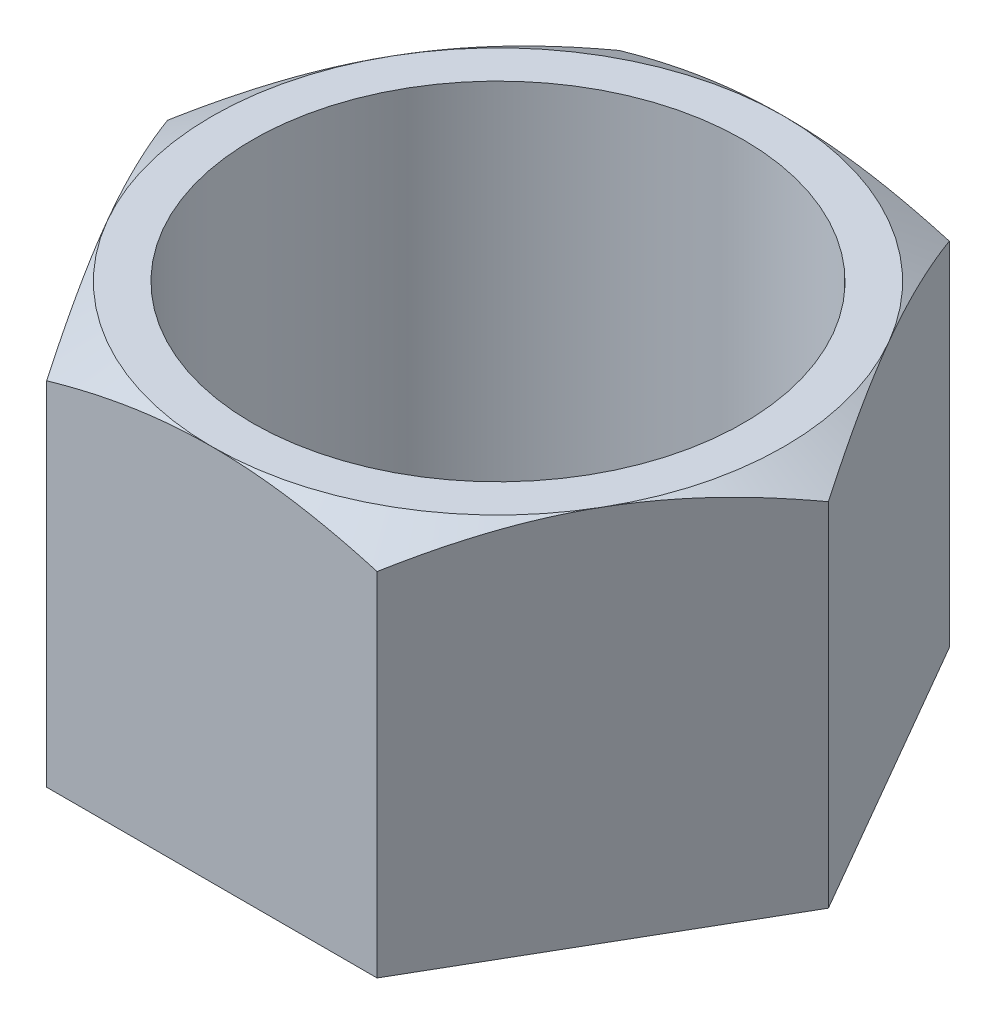
from build123d import *

# Parameters (mm, degrees)
BOSS_EXTRUDE1_DEPTH = 20
SKETCH2_OUTSIDE_W   = 116.37
SKETCH2_OUTSIDE_H   = 111.68
SKETCH2_OUTSIDE_R   = 15.155444566
CUT_EXTRUDE1_DEPTH  = 20
CUT_EXTRUDE1_TAPER  = 60
SKETCH3_R           = 13
CUT_EXTRUDE2_DEPTH  = 21


with BuildPart() as part:
    # Sketch1 → Boss-Extrude1 (new body)
    with BuildSketch(Plane(origin=(0, 0, 0), x_dir=(1, 0, 0), z_dir=(0, 1, 0))):
        Polygon((17.5, 0), (8.75, 15.155444566), (-8.75, 15.155444566), (-17.5, 0), (-8.75, -15.155444566), (8.75, -15.155444566), align=None)
    extrude(amount=BOSS_EXTRUDE1_DEPTH)

    # Sketch2 outside → Cut-Extrude1 (cut)
    with BuildSketch(Plane(origin=(0, 20, 0), x_dir=(1, 0, 0), z_dir=(0, 1, 0))):
        Rectangle(SKETCH2_OUTSIDE_W, SKETCH2_OUTSIDE_H)
        Circle(SKETCH2_OUTSIDE_R, mode=Mode.SUBTRACT)
    extrude(amount=-CUT_EXTRUDE1_DEPTH, taper=CUT_EXTRUDE1_TAPER, mode=Mode.SUBTRACT)

    # Sketch3 → Cut-Extrude2 (cut, through all)
    with BuildSketch(Plane(origin=(0, 20, 0), x_dir=(1, 0, 0), z_dir=(0, 1, 0))):
        Circle(SKETCH3_R)
    extrude(amount=-CUT_EXTRUDE2_DEPTH, mode=Mode.SUBTRACT)


solid = part.part
